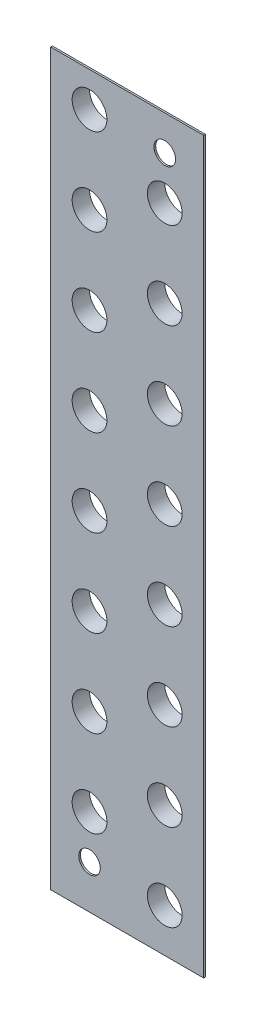
from build123d import *
from build123d.topology import SkipClean

# Parameters (mm, degrees)
SKETCH1_W              = 44
SKETCH1_H              = 210
BOSS_EXTRUDE1_DEPTH    = 0.5
SKETCH7_R              = 5
CUT_EXTRUDE3_DEPTH     = 108.281172626
LPATTERN1_COUNT        = 8
LPATTERN1_PITCH        = 25
SKETCH8_R              = 3.1
CUT_EXTRUDE4_DEPTH     = 108.281172626
SKETCH10_R             = 5.5
SKETCH10_R_2           = 5
BOSS_EXTRUDE3_DEPTH    = 4.5
FILLET2_R              = 0.5
LPATTERN3_COUNT        = 8
LPATTERN3_PITCH        = 25
FILLET2_OF_LPATTERN3_R = 0.5


with BuildPart() as part:
    # Sketch1 → Boss-Extrude1 (new body)
    with BuildSketch(Plane.XY):
        Rectangle(SKETCH1_W, SKETCH1_H)
    extrude(amount=BOSS_EXTRUDE1_DEPTH)

    # Sketch7 → Cut-Extrude3 (cut, through all)
    with BuildSketch(Plane.XY.offset(0.5)):
        with Locations((10.825317547, 82.5)):
            Circle(SKETCH7_R)
        with Locations((-10.825317547, 95)):
            Circle(SKETCH7_R)
    cut_extrude3 = extrude(amount=-CUT_EXTRUDE3_DEPTH, mode=Mode.SUBTRACT)

    # LPattern1: Cut-Extrude3 ×8
    with Locations(*[(0, -i * LPATTERN1_PITCH, 0) for i in range(1, LPATTERN1_COUNT)]):
        add(cut_extrude3, mode=Mode.SUBTRACT)

    # Sketch8 → Cut-Extrude4 (cut, through all)
    with BuildSketch(Plane(origin=(0, 0, 0), x_dir=(-1, 0, 0), z_dir=(0, 0, -1))):
        with Locations((-10.825317547, 95)):
            Circle(SKETCH8_R)
        with Locations((10.825317547, -92.5)):
            Circle(SKETCH8_R)
    extrude(amount=-CUT_EXTRUDE4_DEPTH, mode=Mode.SUBTRACT)

    # Sketch10 → Boss-Extrude3 (add)
    # profile 1 of 2: a face of its own
    with SkipClean():  # the faces are left unmerged after this step: merging them gives an invalid solid
        with BuildSketch(Plane(origin=(0, 0, 0), x_dir=(-1, 0, 0), z_dir=(0, 0, -1))):
            with Locations((-10.825317547, -92.5)):
                Circle(SKETCH10_R)
            with Locations((-10.825317547, -92.5)):
                Circle(SKETCH10_R_2, mode=Mode.SUBTRACT)
        # profile 2 of 2: a face of its own
        with BuildSketch(Plane(origin=(0, 0, 0), x_dir=(-1, 0, 0), z_dir=(0, 0, -1))):
            with Locations((10.825317547, -80)):
                Circle(SKETCH10_R)
            with Locations((10.825317547, -80)):
                Circle(SKETCH10_R_2, mode=Mode.SUBTRACT)
        boss_extrude3 = extrude(amount=BOSS_EXTRUDE3_DEPTH)
    add(part.part.scale(1), mode=Mode.REPLACE)  # the faces are merged on a copy

    # Fillet2
    fillet2_edges = [part.edges().sort_by_distance(p)[0] for p in [
        (-5.325317547, -80, 0),
        (16.325317547, -92.5, 0),
    ]]
    fillet(fillet2_edges, radius=FILLET2_R)

    # LPattern3: Boss-Extrude3 ×8
    with Locations(*[(0, i * LPATTERN3_PITCH, 0) for i in range(1, LPATTERN3_COUNT)]):
        add(boss_extrude3)

    # Fillet2 of LPattern3
    fillet2_of_lpattern3_edges = [part.edges().sort_by_distance(p)[0] for p in [
        (-5.325317547, -55, 0),
        (16.325317547, -67.5, 0),
        (-5.325317547, -30, 0),
        (16.325317547, -42.5, 0),
        (-5.325317547, -5, 0),
        (16.325317547, -17.5, 0),
        (-5.325317547, 20, 0),
        (16.325317547, 7.5, 0),
        (-5.325317547, 45, 0),
        (16.325317547, 32.5, 0),
        (-5.325317547, 70, 0),
        (16.325317547, 57.5, 0),
        (-5.325317547, 95, 0),
        (16.325317547, 82.5, 0),
    ]]
    fillet(fillet2_of_lpattern3_edges, radius=FILLET2_OF_LPATTERN3_R)


solid = part.part
